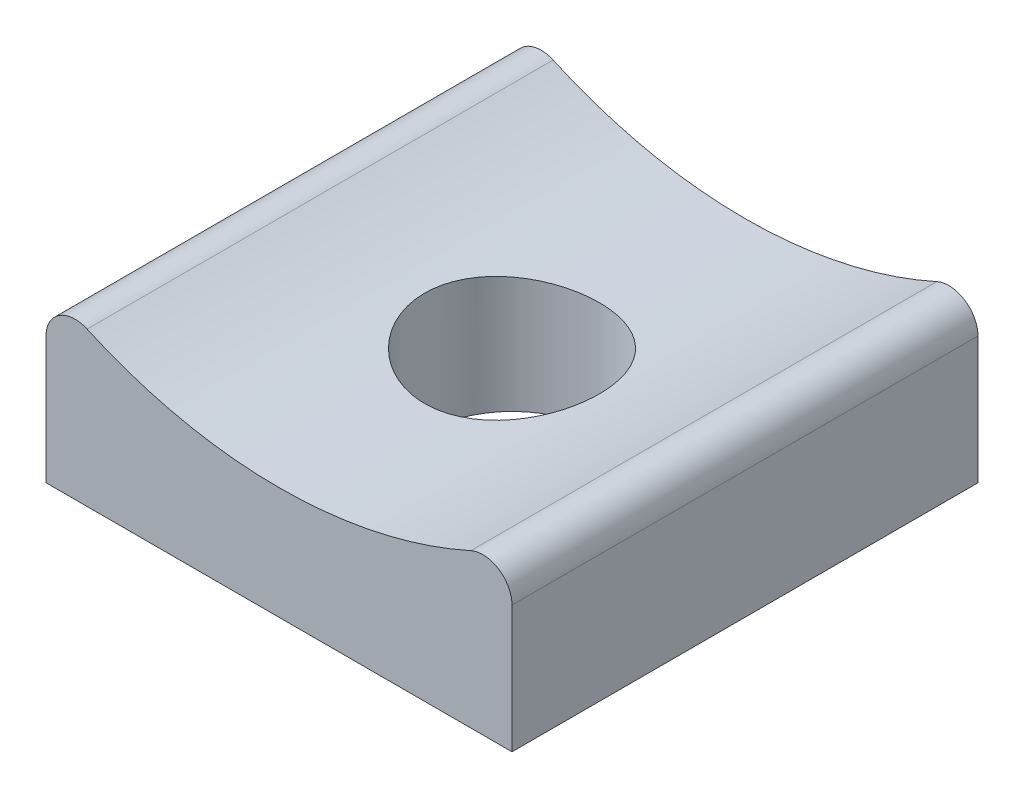
from build123d import *

# Parameters (mm, degrees)
BOSS_EXTRUDE1_DEPTH = 8
FILLET1_R           = 0.5
SKETCH2_R           = 1.5
CUT_EXTRUDE1_DEPTH  = 3.682236538


with BuildPart() as part:
    # Sketch1 → Boss-Extrude1 (new body)
    with BuildSketch(Plane.XY):
        with BuildLine():
            Line((-4, -6.92820323), (-4, -9.92820323))
            Line((-4, -9.92820323), (4, -9.92820323))
            Line((4, -9.92820323), (4, -6.92820323))
            ThreePointArc((4, -6.92820323), (0, -8), (-4, -6.92820323))
        make_face()
    extrude(amount=BOSS_EXTRUDE1_DEPTH)

    # Fillet1
    fillet1_edges = [part.edges().sort_by_distance(p)[0] for p in [
        (4, -6.92820323, 4),
        (-4, -6.92820323, 4),
    ]]
    fillet(fillet1_edges, radius=FILLET1_R)

    # Sketch2 → Cut-Extrude1 (cut, through all)
    with BuildSketch(Plane.XZ.offset(9.92820323)):
        with Locations((0, 4)):
            Circle(SKETCH2_R)
    extrude(amount=-CUT_EXTRUDE1_DEPTH, mode=Mode.SUBTRACT)


solid = part.part
